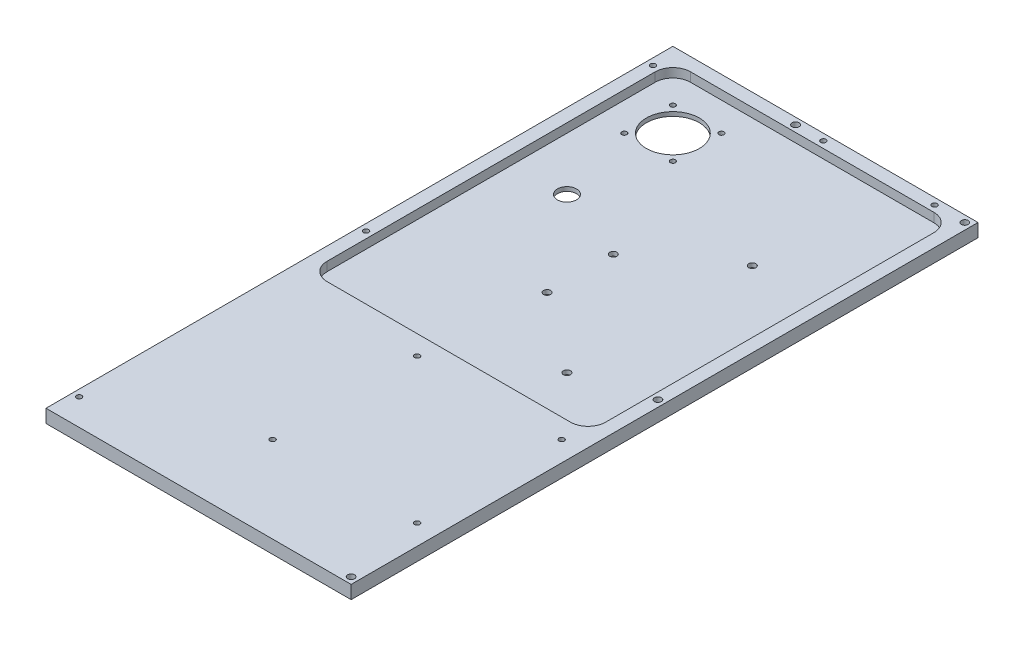
from build123d import *

# Parameters (mm, degrees)
SKETCH1_W                   = 219.525
SKETCH1_H                   = 451
BOSS_EXTRUDE1_DEPTH         = 9.525
SKETCH2_W                   = 200.475
SKETCH2_H                   = 261.475
CUT_EXTRUDE1_DEPTH          = 6.525
FILLET1_R                   = 12.7
F_10_24_TAPPED_HOLE3_D      = 3.7973
F_10_24_TAPPED_HOLE1_D      = 3.7973
SKETCH9_R                   = 19.05
CUT_EXTRUDE2_DEPTH          = 4
F_6_CLEARANCE_HOLE1_D       = 3.6576
F_6_CLEARANCE_HOLE1_DEPTH   = 3
F_6_CLEARANCE_HOLE1_TIP     = 1.0988539
SKETCH12_R                  = 6.858
CUT_EXTRUDE3_DEPTH          = 4
F_10_CLEARANCE_HOLE1_D      = 4.9784
F_10_24_TAPPED_HOLE4_D      = 3.7973
F_10_24_TAPPED_HOLE4_DEPTH  = 18.03
F_10_24_TAPPED_HOLE4_TIP    = 1.140824014
F_10_CLEARANCE_HOLE2_D      = 5.1054
F_10_CLEARANCE_HOLE2_DEPTH  = 135.89
F_10_CLEARANCE_HOLE2_TIP    = 1.533816902
F_1_4_20_TAPPED_HOLE1_D     = 5.1054
F_1_4_20_TAPPED_HOLE1_DEPTH = 17.15
F_1_4_20_TAPPED_HOLE1_TIP   = 1.533816902


with BuildPart() as part:
    # Sketch1 → Boss-Extrude1 (new body)
    with BuildSketch(Plane(origin=(0, 0, 0), x_dir=(1, 0, 0), z_dir=(0, 1, 0))):
        Rectangle(SKETCH1_W, SKETCH1_H)
    extrude(amount=BOSS_EXTRUDE1_DEPTH)

    # Sketch2 → Cut-Extrude1 (cut)
    with BuildSketch(Plane(origin=(0, 9.525, 0), x_dir=(1, 0, 0), z_dir=(0, 1, 0))):
        with Locations((0, 85.2375)):
            Rectangle(SKETCH2_W, SKETCH2_H)
    extrude(amount=-CUT_EXTRUDE1_DEPTH, mode=Mode.SUBTRACT)

    # Fillet1
    fillet1_edges = [part.edges().sort_by_distance(p)[0] for p in [
        (-100.2375, 6.2625, -215.975),
        (100.2375, 6.2625, -215.975),
        (100.2375, 6.2625, 45.5),
        (-100.2375, 6.2625, 45.5),
    ]]
    fillet(fillet1_edges, radius=FILLET1_R)

    # #10-24 Tapped Hole3 (through all)
    with Locations(Plane(origin=(0, 9.525, 0), x_dir=(1, 0, 0), z_dir=(0, 1, 0))):
        with Locations((-8.7375, -59.5), (95.2625, -59.5), (-8.7375, -163.5), (95.2625, -163.5)):
            Hole(F_10_24_TAPPED_HOLE3_D / 2)

    # #10-24 Tapped Hole1 (through all)
    with Locations(Plane(origin=(0, 9.525, 0), x_dir=(1, 0, 0), z_dir=(0, 1, 0))):
        with Locations((83.2625, 220.7375), (3.2625, 220.7375)):
            Hole(F_10_24_TAPPED_HOLE1_D / 2)

    # Sketch9 → Cut-Extrude2 (cut, through all)
    with BuildSketch(Plane(origin=(0, 3, 0), x_dir=(1, 0, 0), z_dir=(0, 1, 0))):
        with Locations(Location((-62.1375, 177.875, 0), (0, 0, 270))):  # turned: the seam where the file's is
            Circle(SKETCH9_R)
    extrude(amount=-CUT_EXTRUDE2_DEPTH, mode=Mode.SUBTRACT)

    # #6 Clearance Hole1
    with Locations(Plane(origin=(0, 3, 0), x_dir=(1, 0, 0), z_dir=(0, 1, 0))):
        with Locations((-44.675, 195.3375), (-62.1375, 177.875), (-44.675, 160.4125), (-79.6, 160.4125), (-79.6, 195.3375)):
            Hole(F_6_CLEARANCE_HOLE1_D / 2, depth=F_6_CLEARANCE_HOLE1_DEPTH)
            with Locations((0, 0, -(F_6_CLEARANCE_HOLE1_DEPTH + F_6_CLEARANCE_HOLE1_TIP / 2))):  # 118° drill point
                Cone(0, F_6_CLEARANCE_HOLE1_D / 2, F_6_CLEARANCE_HOLE1_TIP, mode=Mode.SUBTRACT)

    # Sketch12 → Cut-Extrude3 (cut, through all)
    with BuildSketch(Plane(origin=(0, 3, 0), x_dir=(1, 0, 0), z_dir=(0, 1, 0))):
        with Locations(Location((-62.1375, 101.675, 0), (0, 0, 270))):  # turned: the seam where the file's is
            Circle(SKETCH12_R)
    extrude(amount=-CUT_EXTRUDE3_DEPTH, mode=Mode.SUBTRACT)

    # #10 Clearance Hole1 (through all)
    with Locations(Plane(origin=(0, 9.525, 0), x_dir=(1, 0, 0), z_dir=(0, 1, 0))):
        with Locations((105, 220.7375), (105, 0), (105, -220.7375)):
            Hole(F_10_CLEARANCE_HOLE1_D / 2)

    # #10-24 Tapped Hole4
    with Locations(Plane(origin=(0, 9.525, 0), x_dir=(1, 0, 0), z_dir=(0, 1, 0))):
        with Locations((-105, 206.45), (-105, 0), (-105, -206.45)):
            Hole(F_10_24_TAPPED_HOLE4_D / 2, depth=F_10_24_TAPPED_HOLE4_DEPTH)
            with Locations((0, 0, -(F_10_24_TAPPED_HOLE4_DEPTH + F_10_24_TAPPED_HOLE4_TIP / 2))):  # 118° drill point
                Cone(0, F_10_24_TAPPED_HOLE4_D / 2, F_10_24_TAPPED_HOLE4_TIP, mode=Mode.SUBTRACT)

    # #10 Clearance Hole2
    with Locations(Plane(origin=(0, 3, 0), x_dir=(1, 0, 0), z_dir=(0, 1, 0))):
        with Locations((-8.1625, 81.0375), (-8.1625, 33.4125), (48.9875, 123.9), (48.9875, -9.45)):
            Hole(F_10_CLEARANCE_HOLE2_D / 2, depth=F_10_CLEARANCE_HOLE2_DEPTH)
            with Locations((0, 0, -(F_10_CLEARANCE_HOLE2_DEPTH + F_10_CLEARANCE_HOLE2_TIP / 2))):  # 118° drill point
                Cone(0, F_10_CLEARANCE_HOLE2_D / 2, F_10_CLEARANCE_HOLE2_TIP, mode=Mode.SUBTRACT)

    # 1/4-20 Tapped Hole1
    with Locations(Plane(origin=(0, 9.525, 0), x_dir=(1, 0, 0), z_dir=(0, 1, 0))):
        with Locations((-16.7375, 220.7375)):
            Hole(F_1_4_20_TAPPED_HOLE1_D / 2, depth=F_1_4_20_TAPPED_HOLE1_DEPTH)
            with Locations((0, 0, -(F_1_4_20_TAPPED_HOLE1_DEPTH + F_1_4_20_TAPPED_HOLE1_TIP / 2))):  # 118° drill point
                Cone(0, F_1_4_20_TAPPED_HOLE1_D / 2, F_1_4_20_TAPPED_HOLE1_TIP, mode=Mode.SUBTRACT)


solid = part.part
